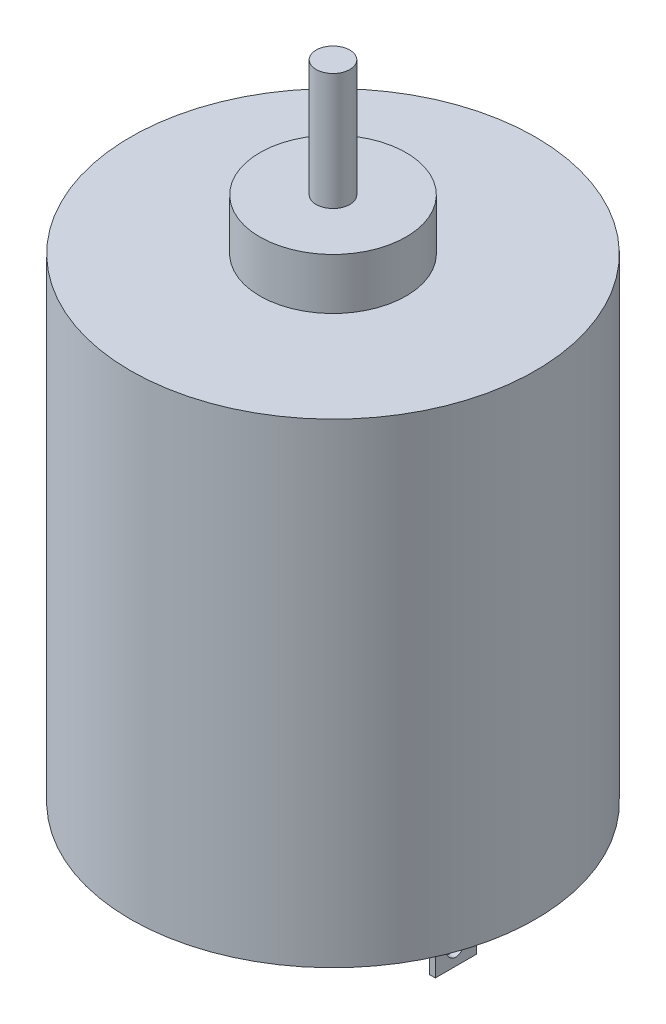
from build123d import *

# Parameters (mm, degrees)
ESQUISSE1_R             = 13.85
BOSS_EXTRU_1_DEPTH      = 32.5
BOSS_EXTRU_2_DEPTH      = 36
BOSS_EXTRU_2_DEPTH_BACK = 2.2
ESQUISSE1_3_R           = 5
BOSS_EXTRU_3_DEPTH      = 44
BOSS_EXTRU_3_DEPTH_BACK = 3
ESQUISSE1_4_R           = 1.1525
ESQUISSE1_5_W           = 0.4
ESQUISSE1_5_H           = 2.8
BOSS_EXTRU_4_DEPTH      = 5.5
ENL_V_MAT_EXTRU_2_REACH = 53.214
ESQUISSE2_RX            = 1.263747853
ESQUISSE2_RY            = 0.805399752
ENL_V_MAT_EXTRU_3_REACH = 53.214
ESQUISSE3_RX            = 1.263747853
ESQUISSE3_RY            = 0.805399752


with BuildPart() as part:
    # Esquisse1 → Boss.-Extru.1 (new body)
    with BuildSketch(Plane(origin=(0, 0, 0), x_dir=(1, 0, 0), z_dir=(0, 1, 0))):
        Circle(ESQUISSE1_R)
    extrude(amount=BOSS_EXTRU_1_DEPTH)

    # Esquisse1_3 → Boss.-Extru.2 (add, two sides: drawn at the far end of the back side and taken through both)
    with BuildSketch(Plane(origin=(0, 0, 0), x_dir=(1, 0, 0), z_dir=(0, 1, 0)).offset(-BOSS_EXTRU_2_DEPTH_BACK)):
        Circle(ESQUISSE1_3_R)
    extrude(amount=BOSS_EXTRU_2_DEPTH + BOSS_EXTRU_2_DEPTH_BACK)

    # Esquisse1_4 → Boss.-Extru.3 (add, two sides: drawn at the far end of the back side and taken through both)
    with BuildSketch(Plane(origin=(0, 0, 0), x_dir=(1, 0, 0), z_dir=(0, 1, 0)).offset(-BOSS_EXTRU_3_DEPTH_BACK)):
        Circle(ESQUISSE1_4_R)
    extrude(amount=BOSS_EXTRU_3_DEPTH + BOSS_EXTRU_3_DEPTH_BACK)

    # Esquisse1_5 → Boss.-Extru.4 (add)
    with BuildSketch(Plane(origin=(0, 0, 0), x_dir=(1, 0, 0), z_dir=(0, 1, 0))):
        with Locations((-8.2, 0)):
            Rectangle(ESQUISSE1_5_W, ESQUISSE1_5_H)
        with Locations((8.2, 0)):
            Rectangle(ESQUISSE1_5_W, ESQUISSE1_5_H)
    extrude(amount=-BOSS_EXTRU_4_DEPTH)

    # Esquisse2 → Enlèv. mat.-Extru.2 (cut, up to next)
    with BuildSketch(Plane.ZY.offset(8.4), mode=Mode.PRIVATE) as enl_v_mat_extru_2_sk1:
        with Locations(Location((0, -3.697573844), (0, 0, 90))):
            Ellipse(ESQUISSE2_RX, ESQUISSE2_RY)
    enl_v_mat_extru_2_tool1 = extrude(enl_v_mat_extru_2_sk1.sketch, amount=-ENL_V_MAT_EXTRU_2_REACH, mode=Mode.PRIVATE) & part.part
    add(enl_v_mat_extru_2_tool1.solids().sort_by_distance((-8.4, -3.697574, 0))[0], mode=Mode.SUBTRACT)

    # Esquisse3 → Enlèv. mat.-Extru.3 (cut, up to next)
    with BuildSketch(Plane(origin=(8.4, 0, 0), x_dir=(0, 0, -1), z_dir=(1, 0, 0)), mode=Mode.PRIVATE) as enl_v_mat_extru_3_sk1:
        with Locations(Location((0, -3.697573844), (0, 0, -90))):
            Ellipse(ESQUISSE3_RX, ESQUISSE3_RY)
    enl_v_mat_extru_3_tool1 = extrude(enl_v_mat_extru_3_sk1.sketch, amount=-ENL_V_MAT_EXTRU_3_REACH, mode=Mode.PRIVATE) & part.part
    add(enl_v_mat_extru_3_tool1.solids().sort_by_distance((8.4, -3.697574, 0))[0], mode=Mode.SUBTRACT)


solid = part.part
